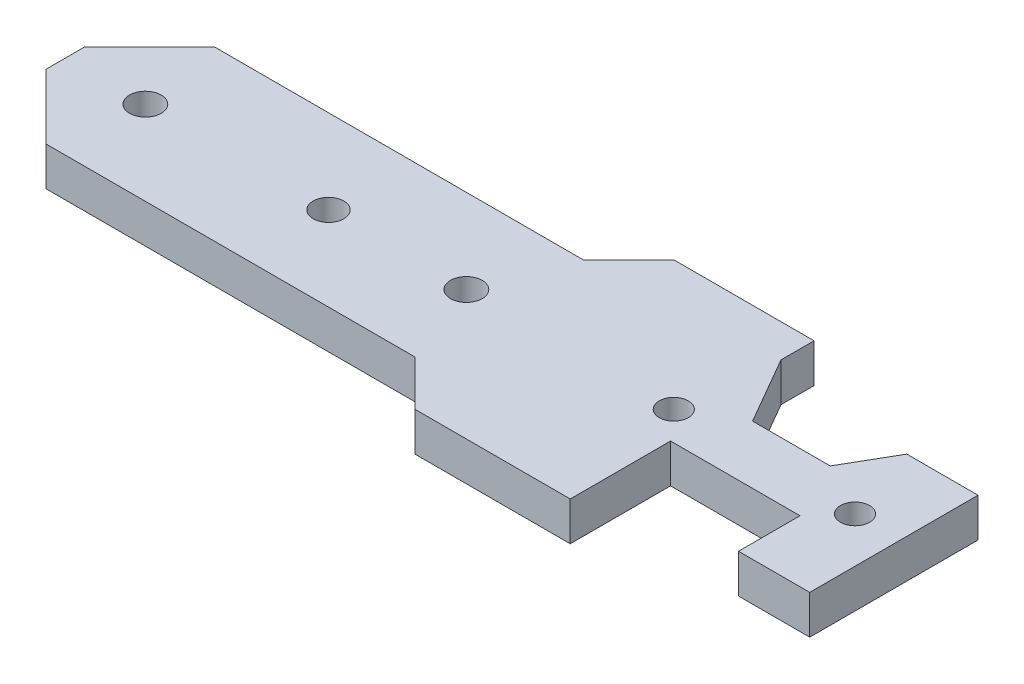
from build123d import *

# Parameters (mm, degrees)
BOSS_EXTRUDE1_DEPTH = 6
SKETCH2_R           = 2.45
SKETCH2_R_2         = 2.375
SKETCH2_R_3         = 2.25
CUT_EXTRUDE1_DEPTH  = 7


with BuildPart() as part:
    # Sketch1 → Boss-Extrude1 (new body)
    with BuildSketch(Plane(origin=(0, 0, 0), x_dir=(1, 0, 0), z_dir=(0, 1, 0))):
        Polygon((10, 13), (67, 13), (74, 20), (95.669872981, 20), (95.669872981, 14.892304845), (101.669872981, 4.5), (113.669872981, 4.5), (118, 12), (129, 12), (129, -14), (118, -14), (118, -4.5), (98, -4.5), (98, -20), (74, -20), (67, -13), (10, -13), (0, -3), (0, 3), align=None)
    extrude(amount=BOSS_EXTRUDE1_DEPTH)

    # Sketch2 → Cut-Extrude1 (cut, through all)
    with BuildSketch(Plane(origin=(0, 6, 0), x_dir=(1, 0, 0), z_dir=(0, 1, 0))):
        with Locations((12.35, 0)):
            Circle(SKETCH2_R)
        with Locations((40.65, 0)):
            Circle(SKETCH2_R_2)
        with Locations((61.95, 0)):
            Circle(SKETCH2_R)
        with Locations((94, 0)):
            Circle(SKETCH2_R_3)
        with Locations((122, 0)):
            Circle(SKETCH2_R_3)
    extrude(amount=-CUT_EXTRUDE1_DEPTH, mode=Mode.SUBTRACT)


solid = part.part
